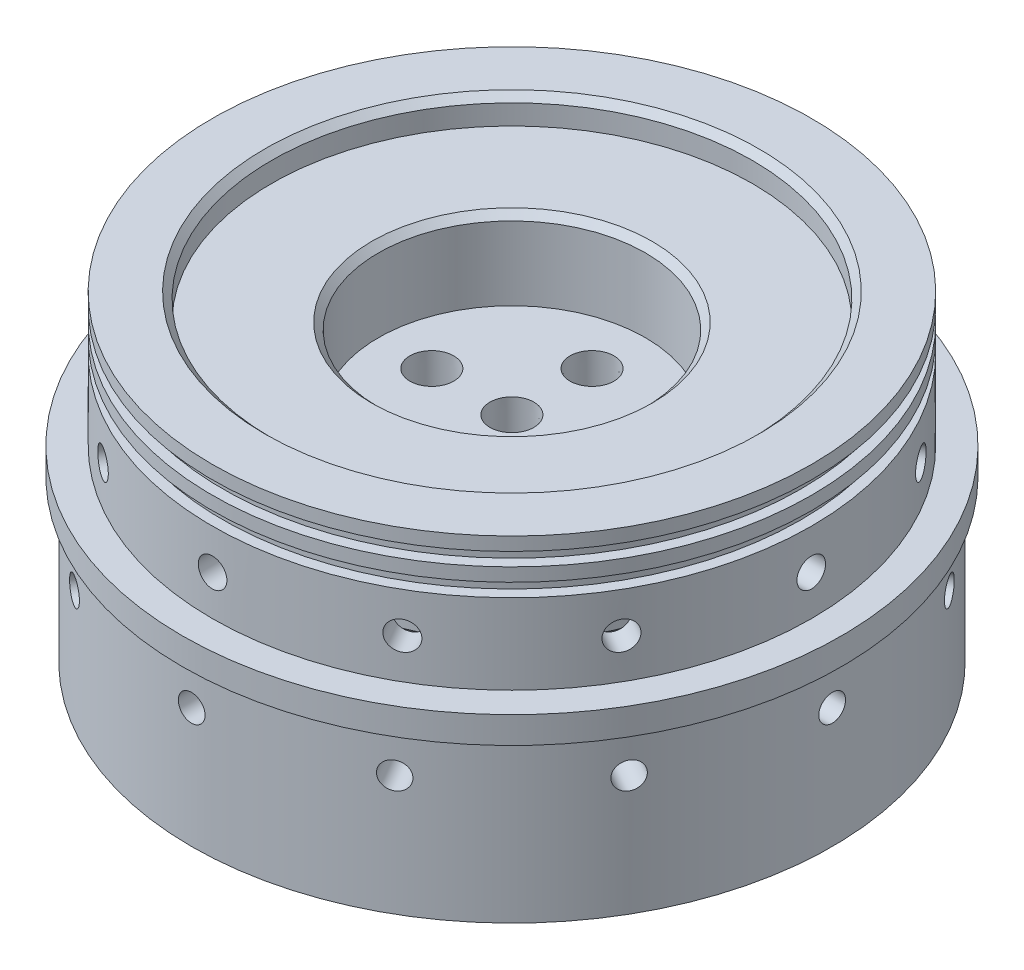
from build123d import *

# Parameters (mm, degrees)
SKETCH1_R                         = 78.359
CENTERRING_TOTOD_THK_DEPTH        = 6.35
SKETCH2_R                         = 71.247
TANKRING_TANKID_HT_DEPTH          = 31.75
SKETCH3_R                         = 76.2
FBRGLSRING_FBRGLSID_HT_DEPTH      = 38.1
SKETCH4_R                         = 65.0875
WALL_BLKHDTHK_DEPTH               = 60.325
SKETCH5_W                         = 2.54
SKETCH5_H                         = 3.175
SKETCH6_R                         = 3.4
TANKBOLTHOLE_DEPTH                = 79.359
TANKBOLTCOUNT_COUNT               = 12
SKETCH7_R                         = 3.175
FBRGLSBOLTHOLE_DEPTH              = 79.359
FBRGLSBOLTCOUNT_COUNT             = 12
SKETCH9_R                         = 71.4375
FBRGLSRINGTRIM_DEPTH              = 19.05
SKETCH10_R                        = 45.847
BOSS_EXTRUDE1_DEPTH               = 25.4
SKETCH13_R                        = 57.15
CUT_EXTRUDE1_DEPTH                = 6.35
SKETCH14_R                        = 31.75
CUT_EXTRUDE2_DEPTH                = 19.05
F_1_8_NPT_TAPPED_HOLE1_AT_2_COUNT = 2
F_1_8_NPT_TAPPED_HOLE1_AT_2_PITCH = 19.05
F_1_8_NPT_TAPPED_HOLE1_AT_3_COUNT = 2
F_1_8_NPT_TAPPED_HOLE1_AT_3_PITCH = 19.05
F_1_8_NPT_TAPPED_HOLE1_AT_4_COUNT = 2
F_1_8_NPT_TAPPED_HOLE1_AT_4_PITCH = 19.05
F_1_8_NPT_TAPPED_HOLE1_AT_5_COUNT = 2
F_1_8_NPT_TAPPED_HOLE1_AT_5_PITCH = 19.05
CHAMFER1_SIZE                     = 1.5875


with BuildPart() as part:
    # Sketch1 → CenterRing(TotOD&Thk) (new body)
    with BuildSketch(Plane(origin=(0, 0, 0), x_dir=(1, 0, 0), z_dir=(0, 1, 0))):
        Circle(SKETCH1_R)
    extrude(amount=CENTERRING_TOTOD_THK_DEPTH)

    # Sketch2 → TankRing(TankID&Ht) (add)
    with BuildSketch(Plane(origin=(0, 6.35, 0), x_dir=(1, 0, 0), z_dir=(0, 1, 0))):
        Circle(SKETCH2_R)
    extrude(amount=TANKRING_TANKID_HT_DEPTH)

    # Sketch3 → FbrGlsRing(FbrGlsID&Ht) (add)
    with BuildSketch(Plane.XZ):
        Circle(SKETCH3_R)
    extrude(amount=FBRGLSRING_FBRGLSID_HT_DEPTH)

    # Sketch4 → Wall&BlkhdThk (cut)
    with BuildSketch(Plane.XZ.offset(38.1)):
        Circle(SKETCH4_R)
    extrude(amount=-WALL_BLKHDTHK_DEPTH, mode=Mode.SUBTRACT)

    # Sketch5 → O-Ring Channel (revolve, cut)
    with BuildSketch(Plane.XY):
        with Locations((-69.977, 33.3375)):
            Rectangle(SKETCH5_W, SKETCH5_H)
        with Locations((-69.977, 26.9875)):
            Rectangle(SKETCH5_W, SKETCH5_H)
    revolve(axis=Axis((0, 6.35, 0), (0, 1, 0)), mode=Mode.SUBTRACT)

    # Sketch6 → TankBoltHole (cut, through all)
    with BuildSketch(Plane.XY):
        with Locations((0, 15.875)):
            Circle(SKETCH6_R)
    tankbolthole = extrude(amount=-TANKBOLTHOLE_DEPTH, mode=Mode.SUBTRACT)

    # TankBoltCount: TankBoltHole ×12 about axis
    tankboltcount_axis = Axis((0, 38.1, 0), (0, -1, 0))
    for i in range(1, TANKBOLTCOUNT_COUNT):
        add(tankbolthole.rotate(tankboltcount_axis, i * 360 / TANKBOLTCOUNT_COUNT), mode=Mode.SUBTRACT)

    # Sketch7 → FbrGlsBoltHole (cut, through all)
    with BuildSketch(Plane.XY):
        with Locations((0, -9.525)):
            Circle(SKETCH7_R)
    fbrglsbolthole = extrude(amount=-FBRGLSBOLTHOLE_DEPTH, mode=Mode.SUBTRACT)

    # FbrGlsBoltCount: FbrGlsBoltHole ×12 about axis
    fbrglsboltcount_axis = Axis((0, -38.1, 0), (0, 1, 0))
    for i in range(1, FBRGLSBOLTCOUNT_COUNT):
        add(fbrglsbolthole.rotate(fbrglsboltcount_axis, i * 360 / FBRGLSBOLTCOUNT_COUNT), mode=Mode.SUBTRACT)

    # Sketch9 → FbrGlsRingTrim (cut)
    with BuildSketch(Plane.XZ.offset(38.1)):
        Circle(SKETCH9_R)
    extrude(amount=-FBRGLSRINGTRIM_DEPTH, mode=Mode.SUBTRACT)

    # Sketch10 → Boss-Extrude1 (add)
    with BuildSketch(Plane.XZ.offset(-22.225)):
        Circle(SKETCH10_R)
    extrude(amount=BOSS_EXTRUDE1_DEPTH)

    # Sketch12 → Cut-Revolve1 (revolve, cut)
    with BuildSketch(Plane(origin=(0, 0, 0), x_dir=(0, 0, -1), z_dir=(1, 0, 0))):
        with BuildLine():
            Line((-45.847, 0.635), (-43.688, 0.635))
            ThreePointArc((-43.688, 0.635), (-43.149184633, 0.858184633), (-42.926, 1.397))
            Line((-42.926, 1.397), (-42.926, 6.985))
            ThreePointArc((-42.926, 6.985), (-43.149184633, 7.523815367), (-43.688, 7.747))
            Line((-43.688, 7.747), (-45.847, 7.747))
            Line((-45.847, 7.747), (-45.847, 0.635))
        make_face()
    revolve(axis=Axis((0, 0, 0), (0, -1, 0)), mode=Mode.SUBTRACT)

    # Sketch13 → Cut-Extrude1 (cut)
    with BuildSketch(Plane(origin=(0, 38.1, 0), x_dir=(1, 0, 0), z_dir=(0, 1, 0))):
        Circle(SKETCH13_R)
    extrude(amount=-CUT_EXTRUDE1_DEPTH, mode=Mode.SUBTRACT)

    # Sketch14 → Cut-Extrude2 (cut)
    with BuildSketch(Plane(origin=(0, 31.75, 0), x_dir=(1, 0, 0), z_dir=(0, 1, 0))):
        Circle(SKETCH14_R)
    extrude(amount=-CUT_EXTRUDE2_DEPTH, mode=Mode.SUBTRACT)

    # Sketch19 → 1/8 NPT Tapped Hole1 (revolve, cut)
    with BuildSketch(Plane(origin=(0, -3.175, 0), x_dir=(0, 0, -1), z_dir=(1, 0, 0))):
        Polygon((0, 0), (0, 41.275), (4.2164, 41.275), (4.2164, 25.4), (4.936189285, 25.4), (5.6966993, 0), align=None)
    f_1_8_npt_tapped_hole1 = revolve(axis=Axis((0, -9.525, 0), (0, 1, 0)), mode=Mode.SUBTRACT)

    # 1/8 NPT Tapped Hole1 at 2: 1/8 NPT Tapped Hole1 ×2
    with Locations(*[(i * F_1_8_NPT_TAPPED_HOLE1_AT_2_PITCH, 0, 0) for i in range(1, F_1_8_NPT_TAPPED_HOLE1_AT_2_COUNT)]):
        add(f_1_8_npt_tapped_hole1, mode=Mode.SUBTRACT)

    # 1/8 NPT Tapped Hole1 at 3: 1/8 NPT Tapped Hole1 ×2
    with Locations(*[(0, 0, i * F_1_8_NPT_TAPPED_HOLE1_AT_3_PITCH) for i in range(1, F_1_8_NPT_TAPPED_HOLE1_AT_3_COUNT)]):
        add(f_1_8_npt_tapped_hole1, mode=Mode.SUBTRACT)

    # 1/8 NPT Tapped Hole1 at 4: 1/8 NPT Tapped Hole1 ×2
    with Locations(*[(0, 0, -i * F_1_8_NPT_TAPPED_HOLE1_AT_4_PITCH) for i in range(1, F_1_8_NPT_TAPPED_HOLE1_AT_4_COUNT)]):
        add(f_1_8_npt_tapped_hole1, mode=Mode.SUBTRACT)

    # 1/8 NPT Tapped Hole1 at 5: 1/8 NPT Tapped Hole1 ×2
    with Locations(*[(-i * F_1_8_NPT_TAPPED_HOLE1_AT_5_PITCH, 0, 0) for i in range(1, F_1_8_NPT_TAPPED_HOLE1_AT_5_COUNT)]):
        add(f_1_8_npt_tapped_hole1, mode=Mode.SUBTRACT)

    # Chamfer1
    chamfer1_edges = [part.edges().sort_by_distance(p)[0] for p in [
        (-45.847, -3.175, 0),
        (-57.15, 38.1, 0),
        (-31.75, 31.75, 0),
    ]]
    chamfer(chamfer1_edges, length=CHAMFER1_SIZE)


solid = part.part
